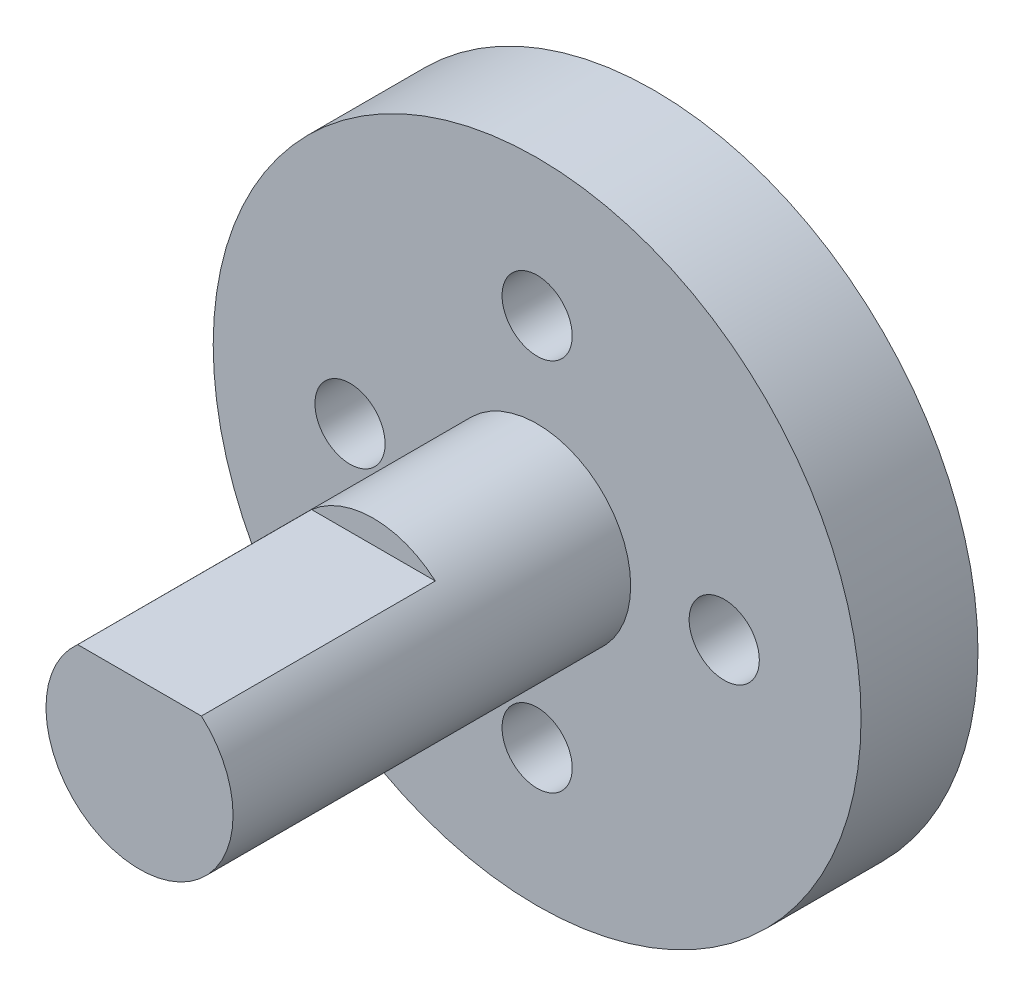
from build123d import *

# Parameters (mm, degrees)
SKETCH2_R                = 13.85
SKETCH2_R_2              = 4
SKETCH2_R_3              = 1.5
BOSS_EXTRUDE1_DEPTH      = 5
SKETCH3_R                = 4
BOSS_EXTRUDE2_DEPTH      = 17
BOSS_EXTRUDE2_DEPTH_BACK = 5
CUT_EXTRUDE1_DEPTH       = 10


with BuildPart() as part:
    # Sketch2 → Boss-Extrude1 (new body)
    with BuildSketch(Plane.XY):
        Circle(SKETCH2_R)
        Circle(SKETCH2_R_2, mode=Mode.SUBTRACT)
        with Locations((0, 8)):
            Circle(SKETCH2_R_3, mode=Mode.SUBTRACT)
        with Locations((-8, 0)):
            Circle(SKETCH2_R_3, mode=Mode.SUBTRACT)
        with Locations((8, 0)):
            Circle(SKETCH2_R_3, mode=Mode.SUBTRACT)
        with Locations((0, -8)):
            Circle(SKETCH2_R_3, mode=Mode.SUBTRACT)
    extrude(amount=BOSS_EXTRUDE1_DEPTH)

    # Sketch3 → Boss-Extrude2 (add, two sides)
    with BuildSketch(Plane.XY.offset(5)) as boss_extrude2_sk:
        Circle(SKETCH3_R)
    extrude(amount=BOSS_EXTRUDE2_DEPTH)
    extrude(boss_extrude2_sk.sketch, amount=-BOSS_EXTRUDE2_DEPTH_BACK)

    # Sketch4 → Cut-Extrude1 (cut)
    with BuildSketch(Plane.XY.offset(22)):
        with BuildLine():
            Line((-2.645751311, 3), (2.645751311, 3))
            ThreePointArc((2.645751311, 3), (0, 4), (-2.645751311, 3))
        make_face()
    extrude(amount=-CUT_EXTRUDE1_DEPTH, mode=Mode.SUBTRACT)


solid = part.part
